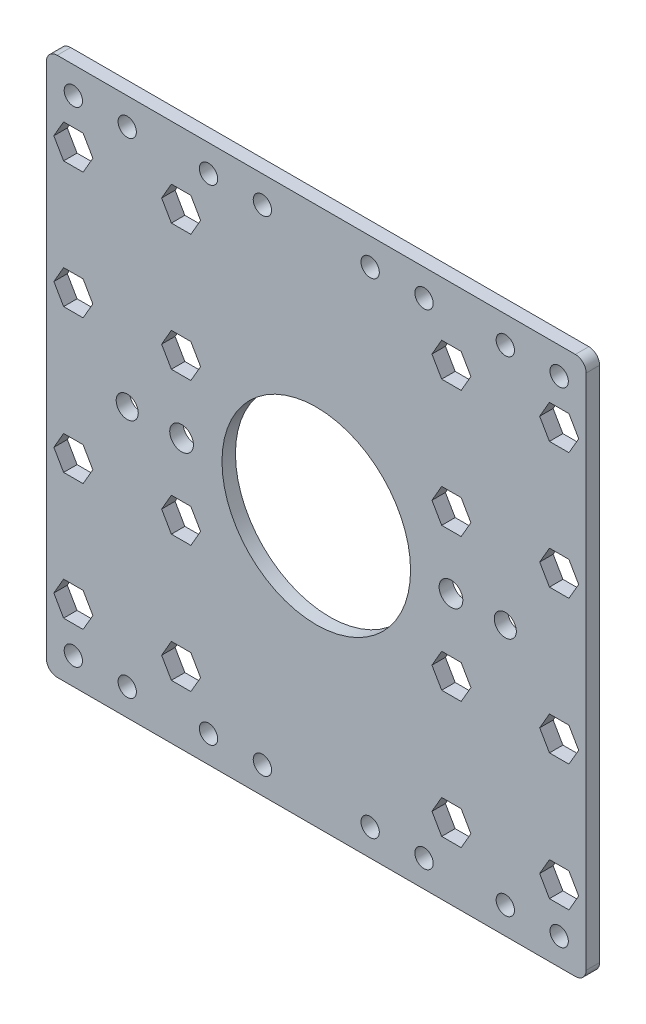
from build123d import *

# Parameters (mm, degrees)
SKIZZE1_R                       = 17.5
SKIZZE1_R_2                     = 2.2
SKIZZE1_R_3                     = 1.7
SKIZZE1_R_4                     = 2.05
AUFSATZ_LINEAR_AUSTRAGEN1_DEPTH = 2.5


with BuildPart() as part:
    # Skizze1 → Aufsatz-Linear austragen1 (new body)
    with BuildSketch(Plane.XY):
        with BuildLine():
            Line((9.914391914, -80), (9.914391914, 0))
            Line((9.914391914, 0), (9.914391914, 8))
            ThreePointArc((9.914391914, 8), (10.500178351, 9.414213562), (11.914391914, 10))
            Line((11.914391914, 10), (108.085608086, 10))
            ThreePointArc((108.085608086, 10), (109.499821649, 9.414213562), (110.085608086, 8))
            Line((110.085608086, 8), (110.085608086, 0))
            Line((110.085608086, 0), (110.085608086, -80))
            Line((110.085608086, -80), (110.085608086, -88))
            ThreePointArc((110.085608086, -88), (109.499821649, -89.414213562), (108.085608086, -90))
            Line((108.085608086, -90), (11.914391914, -90))
            ThreePointArc((11.914391914, -90), (10.500178351, -89.414213562), (9.914391914, -88))
            Line((9.914391914, -88), (9.914391914, -80))
        make_face()
        with Locations((60, -40)):
            Circle(SKIZZE1_R, mode=Mode.SUBTRACT)
        with Locations((35, -40)):
            Circle(SKIZZE1_R_2, mode=Mode.SUBTRACT)
        with Locations((50, -85)):
            Circle(SKIZZE1_R_3, mode=Mode.SUBTRACT)
        with Locations((24.914391914, -40)):
            Circle(SKIZZE1_R_4, mode=Mode.SUBTRACT)
        with Locations((40, -85)):
            Circle(SKIZZE1_R_3, mode=Mode.SUBTRACT)
        with Locations((95.085608086, -85)):
            Circle(SKIZZE1_R_3, mode=Mode.SUBTRACT)
        with Locations((24.914391914, -85)):
            Circle(SKIZZE1_R_3, mode=Mode.SUBTRACT)
        with Locations((14.914391914, -85)):
            Circle(SKIZZE1_R_3, mode=Mode.SUBTRACT)
        with Locations((105.085608086, -85)):
            Circle(SKIZZE1_R_3, mode=Mode.SUBTRACT)
        with Locations((40, 5)):
            Circle(SKIZZE1_R_3, mode=Mode.SUBTRACT)
        with Locations((50, 5)):
            Circle(SKIZZE1_R_3, mode=Mode.SUBTRACT)
        with Locations((70, 5)):
            Circle(SKIZZE1_R_3, mode=Mode.SUBTRACT)
        with Locations((80, 5)):
            Circle(SKIZZE1_R_3, mode=Mode.SUBTRACT)
        with Locations((95.085608086, 5)):
            Circle(SKIZZE1_R_3, mode=Mode.SUBTRACT)
        with Locations((105.085608086, 5)):
            Circle(SKIZZE1_R_3, mode=Mode.SUBTRACT)
        with Locations((80, -85)):
            Circle(SKIZZE1_R_3, mode=Mode.SUBTRACT)
        with Locations((95.085608086, -40)):
            Circle(SKIZZE1_R_4, mode=Mode.SUBTRACT)
        with Locations((70, -85)):
            Circle(SKIZZE1_R_3, mode=Mode.SUBTRACT)
        with Locations((85, -40)):
            Circle(SKIZZE1_R_2, mode=Mode.SUBTRACT)
        with Locations((24.914391914, 5)):
            Circle(SKIZZE1_R_3, mode=Mode.SUBTRACT)
        with Locations((14.914391914, 5)):
            Circle(SKIZZE1_R_3, mode=Mode.SUBTRACT)
        Polygon((101.462722804, -76.748846085), (103.274165445, -79.886356775), (106.897050727, -79.886356775), (108.708493369, -76.748846085), (106.897050727, -73.611335396), (103.274165445, -73.611335396), align=None, mode=Mode.SUBTRACT)
        Polygon((33.107285571, -56.381153914), (31.300179229, -53.251153914), (33.107285571, -50.121153914), (36.721498256, -50.121153914), (38.528604599, -53.251153914), (36.721498256, -56.381153914), align=None, mode=Mode.SUBTRACT)
        Polygon((18.537277196, -3.251153914), (16.725834555, -0.113643225), (13.102949273, -0.113643225), (11.291506631, -3.251153914), (13.102949273, -6.388664604), (16.725834555, -6.388664604), align=None, mode=Mode.SUBTRACT)
        Polygon((38.528604599, -3.251153914), (36.721498256, -0.121153914), (33.107285571, -0.121153914), (31.300179229, -3.251153914), (33.107285571, -6.381153914), (36.721498256, -6.381153914), align=None, mode=Mode.SUBTRACT)
        Polygon((18.528604599, -26.674423043), (16.721498256, -23.544423043), (13.107285571, -23.544423043), (11.300179229, -26.674423043), (13.107285571, -29.804423043), (16.721498256, -29.804423043), align=None, mode=Mode.SUBTRACT)
        Polygon((31.300179229, -26.748846085), (33.107285571, -29.878846085), (36.721498256, -29.878846085), (38.528604599, -26.748846085), (36.721498256, -23.618846085), (33.107285571, -23.618846085), align=None, mode=Mode.SUBTRACT)
        Polygon((16.721498256, -50.195576957), (18.528604599, -53.325576957), (16.721498256, -56.455576957), (13.107285571, -56.455576957), (11.300179229, -53.325576957), (13.107285571, -50.195576957), align=None, mode=Mode.SUBTRACT)
        Polygon((36.721498256, -73.618846085), (38.528604599, -76.748846085), (36.721498256, -79.878846085), (33.107285571, -79.878846085), (31.300179229, -76.748846085), (33.107285571, -73.618846085), align=None, mode=Mode.SUBTRACT)
        Polygon((16.725834555, -73.611335396), (18.537277196, -76.748846085), (16.725834555, -79.886356775), (13.102949273, -79.886356775), (11.291506631, -76.748846085), (13.102949273, -73.611335396), align=None, mode=Mode.SUBTRACT)
        Polygon((81.471395401, -76.748846085), (83.278501744, -79.878846085), (86.892714429, -79.878846085), (88.699820771, -76.748846085), (86.892714429, -73.618846085), (83.278501744, -73.618846085), align=None, mode=Mode.SUBTRACT)
        Polygon((101.471395401, -53.325576957), (103.278501744, -56.455576957), (106.892714429, -56.455576957), (108.699820771, -53.325576957), (106.892714429, -50.195576957), (103.278501744, -50.195576957), align=None, mode=Mode.SUBTRACT)
        Polygon((88.699820771, -53.251153914), (86.892714429, -50.121153914), (83.278501744, -50.121153914), (81.471395401, -53.251153914), (83.278501744, -56.381153914), (86.892714429, -56.381153914), align=None, mode=Mode.SUBTRACT)
        Polygon((86.892714429, -23.618846085), (88.699820771, -26.748846085), (86.892714429, -29.878846085), (83.278501744, -29.878846085), (81.471395401, -26.748846085), (83.278501744, -23.618846085), align=None, mode=Mode.SUBTRACT)
        Polygon((103.278501744, -29.804423043), (101.471395401, -26.674423043), (103.278501744, -23.544423043), (106.892714429, -23.544423043), (108.699820771, -26.674423043), (106.892714429, -29.804423043), align=None, mode=Mode.SUBTRACT)
        Polygon((83.278501744, -6.381153914), (81.471395401, -3.251153914), (83.278501744, -0.121153914), (86.892714429, -0.121153914), (88.699820771, -3.251153914), (86.892714429, -6.381153914), align=None, mode=Mode.SUBTRACT)
        Polygon((103.274165445, -6.388664604), (101.462722804, -3.251153914), (103.274165445, -0.113643225), (106.897050727, -0.113643225), (108.708493369, -3.251153914), (106.897050727, -6.388664604), align=None, mode=Mode.SUBTRACT)
    extrude(amount=AUFSATZ_LINEAR_AUSTRAGEN1_DEPTH)


solid = part.part
